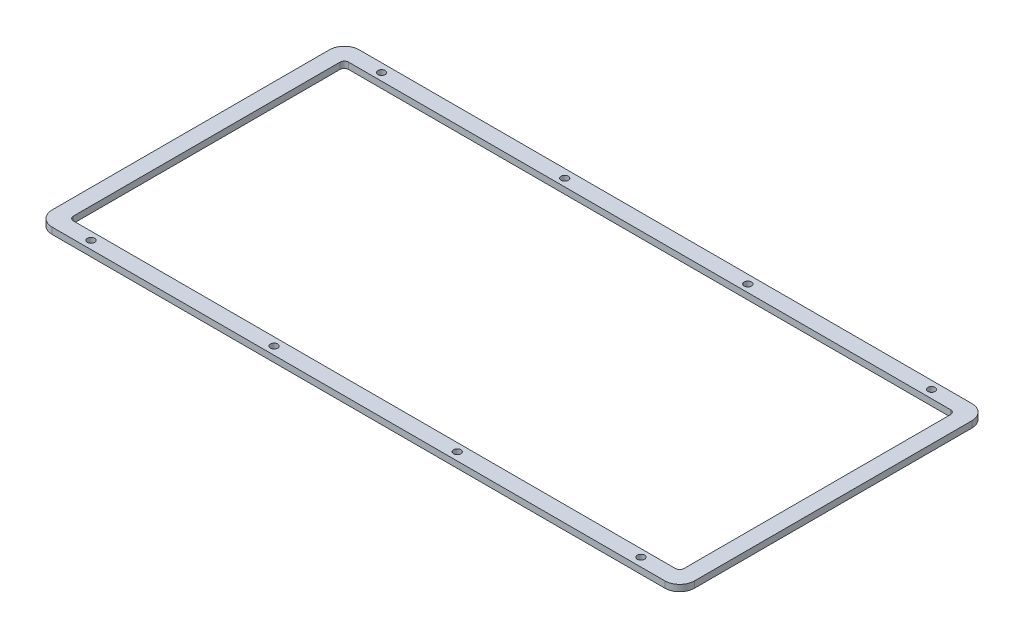
from build123d import *

# Parameters (mm, degrees)
SKETCH1_W           = 350
SKETCH1_H           = 200
BOSS_EXTRUDE1_DEPTH = 3
SKETCH2_OUTSIDE_W   = 432.624
SKETCH2_OUTSIDE_H   = 282.624
SKETCH2_OUTSIDE_R   = 1.7
CUT_EXTRUDE1_DEPTH  = 10


with BuildPart() as part:
    # Sketch1 → Boss-Extrude1 (new body)
    with BuildSketch(Plane(origin=(0, 0, 0), x_dir=(1, 0, 0), z_dir=(0, 1, 0))):
        with Locations((175, 100)):
            Rectangle(SKETCH1_W, SKETCH1_H)
    extrude(amount=BOSS_EXTRUDE1_DEPTH)

    # Sketch2 outside → Cut-Extrude1 (cut)
    with BuildSketch(Plane(origin=(0, 3, 0), x_dir=(1, 0, 0), z_dir=(0, 1, 0))):
        with Locations((175, 100)):
            Rectangle(SKETCH2_OUTSIDE_W, SKETCH2_OUTSIDE_H)
        with BuildLine():
            Line((23.784579293, 37.646381187), (23.784579293, 167.845841187))
            ThreePointArc((23.784579293, 167.845841187), (25.834831825, 172.795588656), (30.784579293, 174.845841187))
            Line((30.784579293, 174.845841187), (318.483929293, 174.845841187))
            ThreePointArc((318.483929293, 174.845841187), (323.433676762, 172.795588656), (325.483929293, 167.845841187))
            Line((325.483929293, 167.845841187), (325.483929293, 37.646381187))
            ThreePointArc((325.483929293, 37.646381187), (323.433676762, 32.696633719), (318.483929293, 30.646381187))
            Line((318.483929293, 30.646381187), (30.784579293, 30.646381187))
            ThreePointArc((30.784579293, 30.646381187), (25.834831825, 32.696633719), (23.784579293, 37.646381187))
        make_face(mode=Mode.SUBTRACT)
        with Locations((303.284579293, 34.646381187)):
            Circle(SKETCH2_OUTSIDE_R)
        with Locations((217.284579293, 34.396381187)):
            Circle(SKETCH2_OUTSIDE_R)
        with Locations((45.284579293, 34.396381187)):
            Circle(SKETCH2_OUTSIDE_R)
        with Locations((131.284579293, 34.396381187)):
            Circle(SKETCH2_OUTSIDE_R)
        with Locations((303.284579293, 171.095841187)):
            Circle(SKETCH2_OUTSIDE_R)
        with Locations((217.284579293, 170.845841187)):
            Circle(SKETCH2_OUTSIDE_R)
        with Locations((45.284579293, 170.845841187)):
            Circle(SKETCH2_OUTSIDE_R)
        with Locations((131.284579293, 170.845841187)):
            Circle(SKETCH2_OUTSIDE_R)
        with BuildLine():
            Line((33.284579293, 167.345841187), (315.983929293, 167.345841187))
            ThreePointArc((315.983929293, 167.345841187), (317.398142856, 166.76005475), (317.983929293, 165.345841187))
            Line((317.983929293, 165.345841187), (317.983929293, 40.146381187))
            ThreePointArc((317.983929293, 40.146381187), (317.398142856, 38.732167625), (315.983929293, 38.146381187))
            Line((315.983929293, 38.146381187), (33.284579293, 38.146381187))
            ThreePointArc((33.284579293, 38.146381187), (31.870365731, 38.732167625), (31.284579293, 40.146381187))
            Line((31.284579293, 40.146381187), (31.284579293, 165.345841187))
            ThreePointArc((31.284579293, 165.345841187), (31.870365731, 166.76005475), (33.284579293, 167.345841187))
        make_face()
    extrude(amount=-CUT_EXTRUDE1_DEPTH, mode=Mode.SUBTRACT)


solid = part.part
